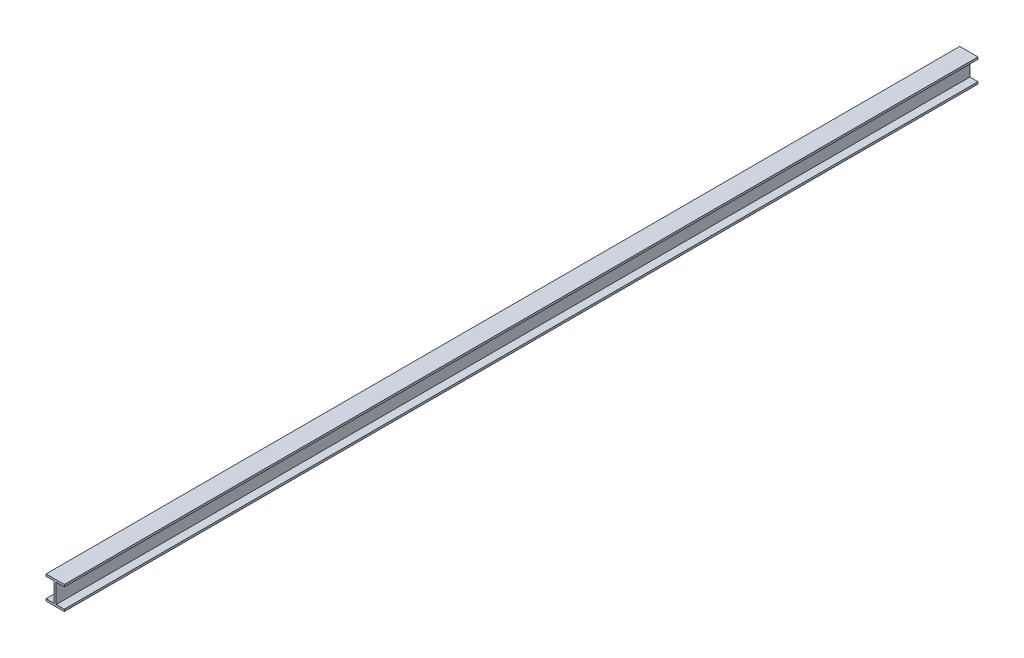
from build123d import *

# Parameters (mm, degrees)
BOSS_EXTRUDE1_DEPTH = 14000


with BuildPart() as part:
    # Sketch1 → Boss-Extrude1 (new body)
    with BuildSketch(Plane.XY):
        Polygon((156, -328), (280, -328), (280, -360), (0, -360), (0, -328), (124, -328), (124, -32), (0, -32), (0, 0), (280, 0), (280, -32), (156, -32), align=None)
    extrude(amount=BOSS_EXTRUDE1_DEPTH)


solid = part.part
